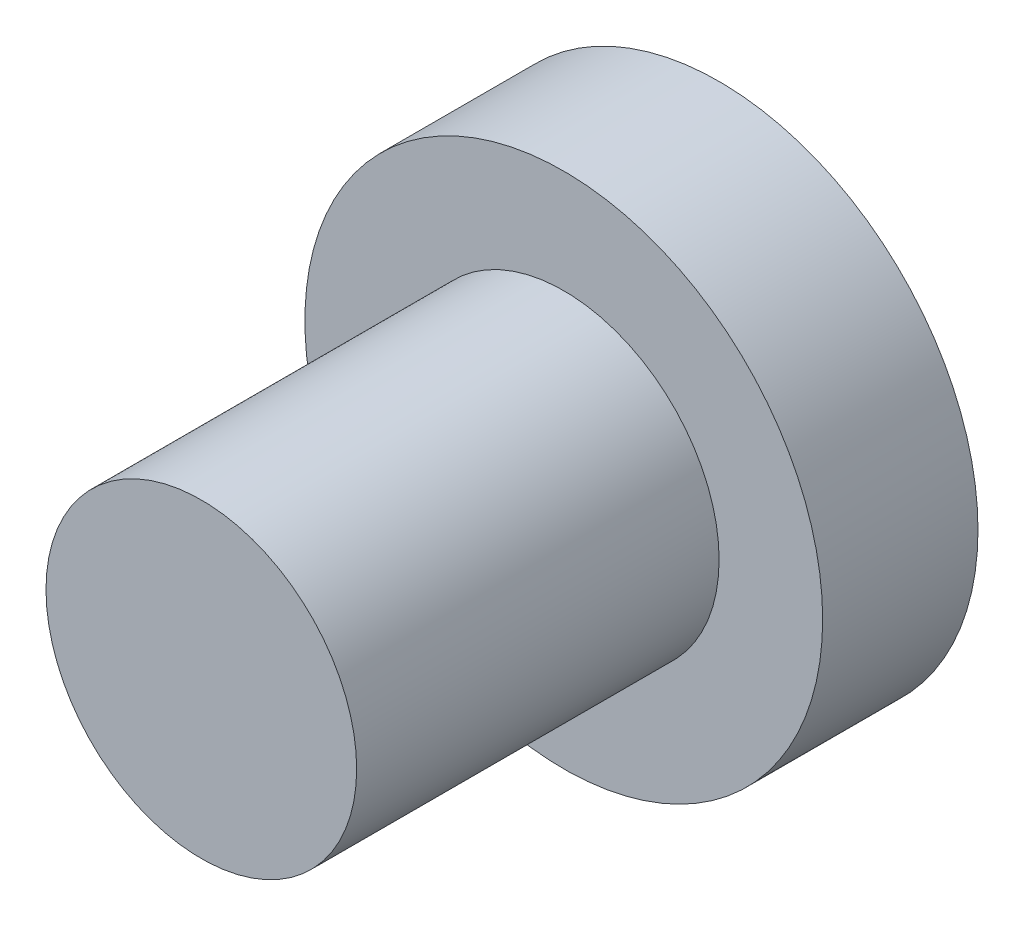
from build123d import *

# Parameters (mm, degrees)
SKETCH1_R           = 5
BOSS_EXTRUDE1_DEPTH = 3
SKETCH2_R           = 3
BOSS_EXTRUDE2_DEPTH = 7


with BuildPart() as part:
    # Sketch1 → Boss-Extrude1 (new body)
    with BuildSketch(Plane.XY):
        Circle(SKETCH1_R)
    extrude(amount=BOSS_EXTRUDE1_DEPTH)

    # Sketch2 → Boss-Extrude2 (add)
    with BuildSketch(Plane.XY.offset(3)):
        Circle(SKETCH2_R)
    extrude(amount=BOSS_EXTRUDE2_DEPTH)


solid = part.part
